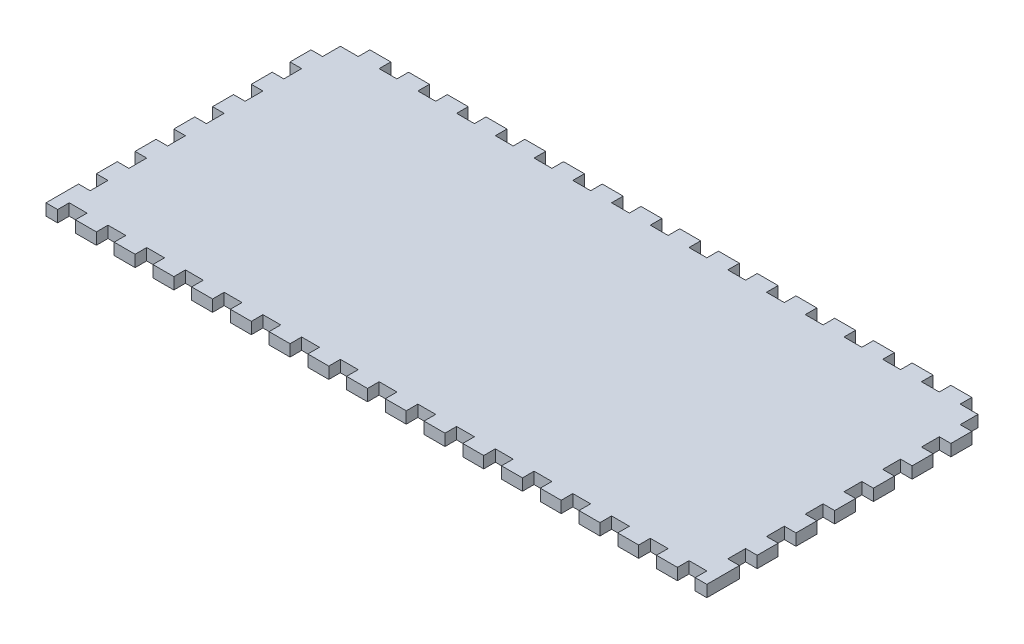
from build123d import *

# Parameters (mm, degrees)
EXTRUDE_1_DEPTH = 3


with BuildPart() as part:
    # Эскиз1 → Бобышка-Вытянуть1 (new body)
    with BuildSketch(Plane(origin=(0, 0, 0), x_dir=(1, 0, 0), z_dir=(0, 1, 0))):
        Polygon((4.6, 70), (4.6, 73), (10, 73), (10, 70), (14.6, 70), (14.6, 73), (20, 73), (20, 70), (24.6, 70), (24.6, 73), (30, 73), (30, 70), (34.6, 70), (34.6, 73), (40, 73), (40, 70), (44.6, 70), (44.6, 73), (50, 73), (50, 70), (54.6, 70), (54.6, 73), (60, 73), (60, 70), (64.6, 70), (64.6, 73), (70, 73), (70, 70), (74.6, 70), (74.6, 73), (80, 73), (80, 70), (84.6, 70), (84.6, 73), (90, 73), (90, 70), (94.6, 70), (94.6, 73), (100, 73), (100, 70), (104.6, 70), (104.6, 73), (110, 73), (110, 70), (114.6, 70), (114.6, 73), (120, 73), (120, 70), (124.6, 70), (124.6, 73), (130, 73), (130, 70), (134.6, 70), (134.6, 73), (140, 73), (140, 70), (144.6, 70), (144.6, 73), (150, 73), (150, 70), (154.6, 70), (154.6, 73), (160, 73), (160, 70), (164.6, 70), (164.6, 65.4), (167.6, 65.4), (167.6, 60), (164.6, 60), (164.6, 55.4), (167.6, 55.4), (167.6, 50), (164.6, 50), (164.6, 45.4), (167.6, 45.4), (167.6, 40), (164.6, 40), (164.6, 35.4), (167.6, 35.4), (167.6, 30), (164.6, 30), (164.6, 25.4), (167.6, 25.4), (167.6, 20), (164.6, 20), (164.6, 15.4), (167.6, 15.4), (167.6, 10), (164.6, 10), (164.6, 5.4), (167.6, 5.4), (167.6, -3), (164.6, -3), (164.6, 0), (160, 0), (160, -3), (154.6, -3), (154.6, 0), (150, 0), (150, -3), (144.6, -3), (144.6, 0), (140, 0), (140, -3), (134.6, -3), (134.6, 0), (130, 0), (130, -3), (124.6, -3), (124.6, 0), (120, 0), (120, -3), (114.6, -3), (114.6, 0), (110, 0), (110, -3), (104.6, -3), (104.6, 0), (100, 0), (100, -3), (94.6, -3), (94.6, 0), (90, 0), (90, -3), (84.6, -3), (84.6, 0), (80, 0), (80, -3), (74.6, -3), (74.6, 0), (70, 0), (70, -3), (64.6, -3), (64.6, 0), (60, 0), (60, -3), (54.6, -3), (54.6, 0), (50, 0), (50, -3), (44.6, -3), (44.6, 0), (40, 0), (40, -3), (34.6, -3), (34.6, 0), (30, 0), (30, -3), (24.6, -3), (24.6, 0), (20, 0), (20, -3), (14.6, -3), (14.6, 0), (10, 0), (10, -3), (4.6, -3), (4.6, 0), (0, 0), (0, -3), (-3, -3), (-3, 5.4), (0, 5.4), (0, 10), (-3, 10), (-3, 15.4), (0, 15.4), (0, 20), (-3, 20), (-3, 25.4), (0, 25.4), (0, 30), (-3, 30), (-3, 35.4), (0, 35.4), (0, 40), (-3, 40), (-3, 45.4), (0, 45.4), (0, 50), (-3, 50), (-3, 55.4), (0, 55.4), (0, 60), (-3, 60), (-3, 65.4), (0, 65.4), (0, 70), align=None)
    extrude(amount=EXTRUDE_1_DEPTH)


solid = part.part
